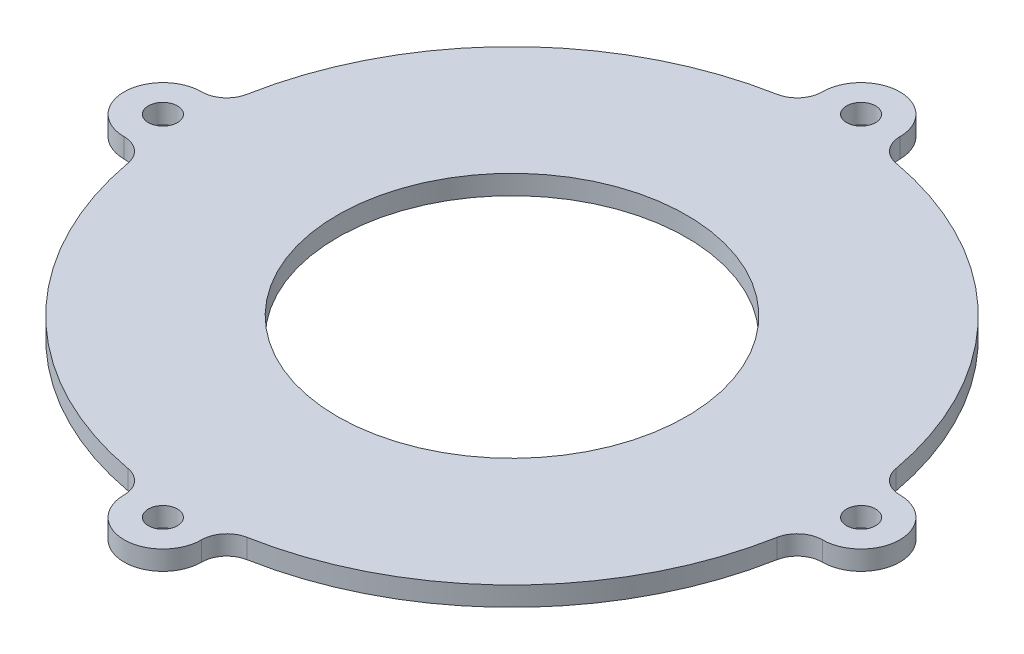
from build123d import *

# Parameters (mm, degrees)
SKETCH1_R           = 1.5
SKETCH1_R_2         = 18
BOSS_EXTRUDE1_DEPTH = 2
SKETCH1_3_R         = 31
SKETCH1_3_R_2       = 25
BOSS_EXTRUDE2_DEPTH = 1


with BuildPart() as part:
    # Sketch1 → Boss-Extrude1 (new body)
    with BuildSketch(Plane(origin=(0, 0, 0), x_dir=(1, 0, 0), z_dir=(0, 1, 0))):
        with BuildLine():
            ThreePointArc((33.442622951, -6.131147541), (34.335520561, -4.602624673), (36, -4))
            ThreePointArc((36, -4), (40, 0), (36, 4))
            ThreePointArc((36, 4), (34.335520561, 4.602624673), (33.442622951, 6.131147541))
            ThreePointArc((33.442622951, 6.131147541), (24.04163056, 24.04163056), (6.131147541, 33.442622951))
            ThreePointArc((6.131147541, 33.442622951), (4.602624673, 34.335520561), (4, 36))
            ThreePointArc((4, 36), (0, 40), (-4, 36))
            ThreePointArc((-4, 36), (-4.602624673, 34.335520561), (-6.131147541, 33.442622951))
            ThreePointArc((-6.131147541, 33.442622951), (-24.04163056, 24.04163056), (-33.442622951, 6.131147541))
            ThreePointArc((-33.442622951, 6.131147541), (-34.335520561, 4.602624673), (-36, 4))
            ThreePointArc((-36, 4), (-40, 0), (-36, -4))
            ThreePointArc((-36, -4), (-34.335520561, -4.602624673), (-33.442622951, -6.131147541))
            ThreePointArc((-33.442622951, -6.131147541), (-24.04163056, -24.04163056), (-6.131147541, -33.442622951))
            ThreePointArc((-6.131147541, -33.442622951), (-4.602624673, -34.335520561), (-4, -36))
            ThreePointArc((-4, -36), (0, -40), (4, -36))
            ThreePointArc((4, -36), (4.602624673, -34.335520561), (6.131147541, -33.442622951))
            ThreePointArc((6.131147541, -33.442622951), (24.04163056, -24.04163056), (33.442622951, -6.131147541))
        make_face()
        with Locations((36, 0)):
            Circle(SKETCH1_R, mode=Mode.SUBTRACT)
        with Locations((0, -36)):
            Circle(SKETCH1_R, mode=Mode.SUBTRACT)
        with Locations((-36, 0)):
            Circle(SKETCH1_R, mode=Mode.SUBTRACT)
        with Locations((0, 36)):
            Circle(SKETCH1_R, mode=Mode.SUBTRACT)
        Circle(SKETCH1_R_2, mode=Mode.SUBTRACT)
    extrude(amount=BOSS_EXTRUDE1_DEPTH)

    # Sketch1_3 → Boss-Extrude2 (add)
    with BuildSketch(Plane(origin=(0, 0, 0), x_dir=(1, 0, 0), z_dir=(0, 1, 0))):
        Circle(SKETCH1_3_R)
        Circle(SKETCH1_3_R_2, mode=Mode.SUBTRACT)
    extrude(amount=-BOSS_EXTRUDE2_DEPTH)


solid = part.part
